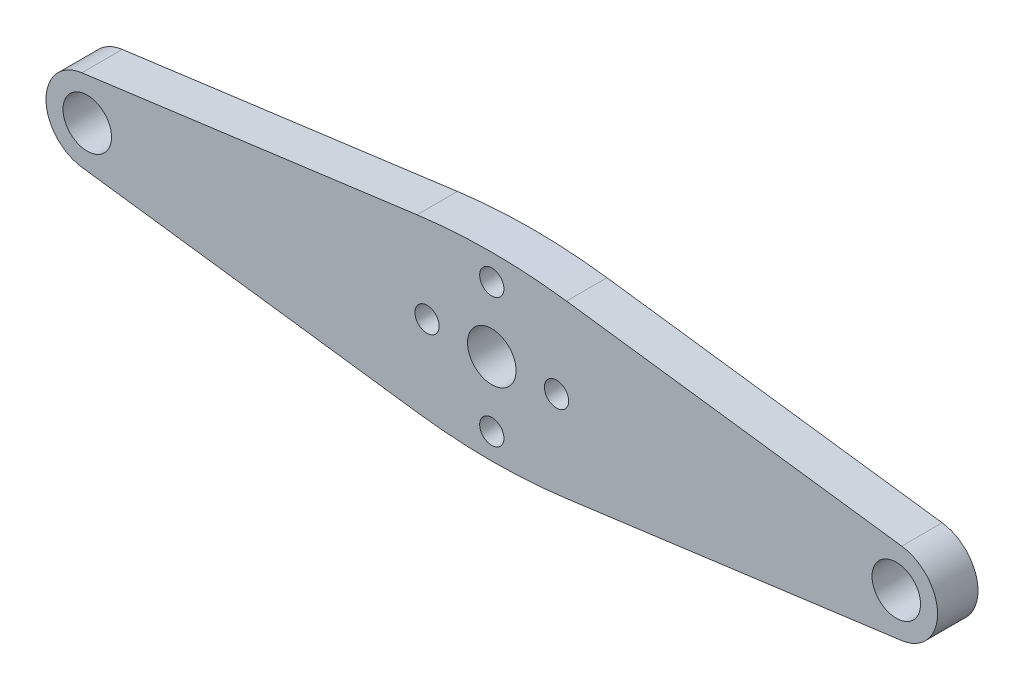
from build123d import *

# Parameters (mm, degrees)
SZKIC1_R                    = 3
SZKIC1_R_2                  = 1.5
DODANIE_WYCI_GNI_CIE1_DEPTH = 5


with BuildPart() as part:
    # Szkic1 → Dodanie-wyciągnięcie1 (new body)
    with BuildSketch(Plane.XY):
        with BuildLine():
            Line((-50.67287635, 5.055665151), (-9.235111676, 10.570763761))
            ThreePointArc((-9.235111676, 10.570763761), (0, 11.182632843), (9.235111676, 10.570763761))
            Line((9.235111676, 10.570763761), (50.67287635, 5.055665151))
            ThreePointArc((50.67287635, 5.055665151), (55.100246338, 0), (50.67287635, -5.055665151))
            Line((50.67287635, -5.055665151), (9.235111676, -10.570763761))
            ThreePointArc((9.235111676, -10.570763761), (0, -11.182632843), (-9.235111676, -10.570763761))
            Line((-9.235111676, -10.570763761), (-50.67287635, -5.055665151))
            ThreePointArc((-50.67287635, -5.055665151), (-55.100246338, 0), (-50.67287635, 5.055665151))
        make_face()
        Circle(SZKIC1_R, mode=Mode.SUBTRACT)
        with Locations((0, 8)):
            Circle(SZKIC1_R_2, mode=Mode.SUBTRACT)
        with Locations((-8, 0)):
            Circle(SZKIC1_R_2, mode=Mode.SUBTRACT)
        with Locations((8, 0)):
            Circle(SZKIC1_R_2, mode=Mode.SUBTRACT)
        with Locations((0, -8)):
            Circle(SZKIC1_R_2, mode=Mode.SUBTRACT)
        with Locations((-50, 0)):
            Circle(SZKIC1_R, mode=Mode.SUBTRACT)
        with Locations((50, 0)):
            Circle(SZKIC1_R, mode=Mode.SUBTRACT)
    extrude(amount=DODANIE_WYCI_GNI_CIE1_DEPTH)


solid = part.part
